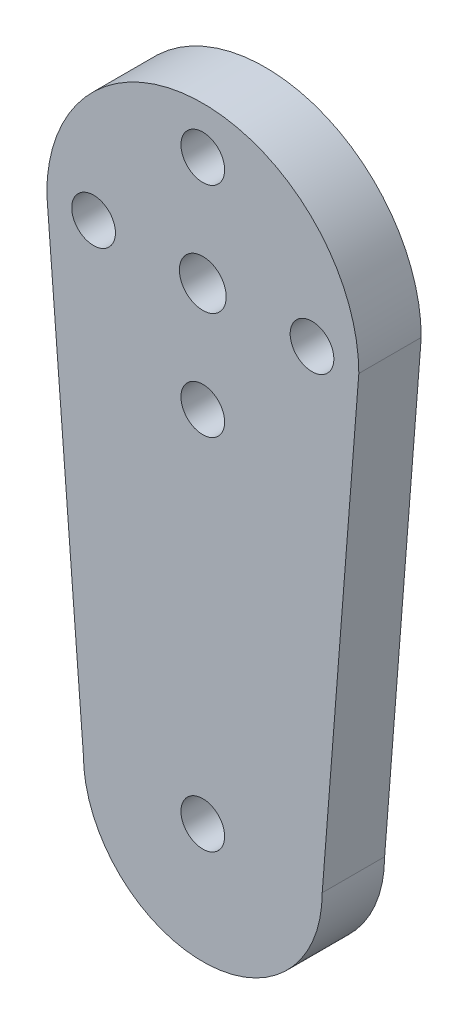
from build123d import *

# Parameters (mm, degrees)
SKETCH1_R           = 1.5
SKETCH1_R_2         = 1.4
BOSS_EXTRUDE1_DEPTH = 4


with BuildPart() as part:
    # Sketch1 → Boss-Extrude1 (new body)
    with BuildSketch(Plane.XY):
        with BuildLine():
            Line((-10, 0), (-7.652901889, -30))
            ThreePointArc((-7.652901889, -30), (0, -37.652901889), (7.652901889, -30))
            Line((7.652901889, -30), (10, 0))
            ThreePointArc((10, 0), (0, 10), (-10, 0))
        make_face()
        Circle(SKETCH1_R, mode=Mode.SUBTRACT)
        with Locations((7, 0)):
            Circle(SKETCH1_R_2, mode=Mode.SUBTRACT)
        with Locations((0, -7)):
            Circle(SKETCH1_R_2, mode=Mode.SUBTRACT)
        with Locations((-7, 0)):
            Circle(SKETCH1_R_2, mode=Mode.SUBTRACT)
        with Locations((0, 7)):
            Circle(SKETCH1_R_2, mode=Mode.SUBTRACT)
        with Locations((0, -30)):
            Circle(SKETCH1_R_2, mode=Mode.SUBTRACT)
    extrude(amount=BOSS_EXTRUDE1_DEPTH)


solid = part.part
